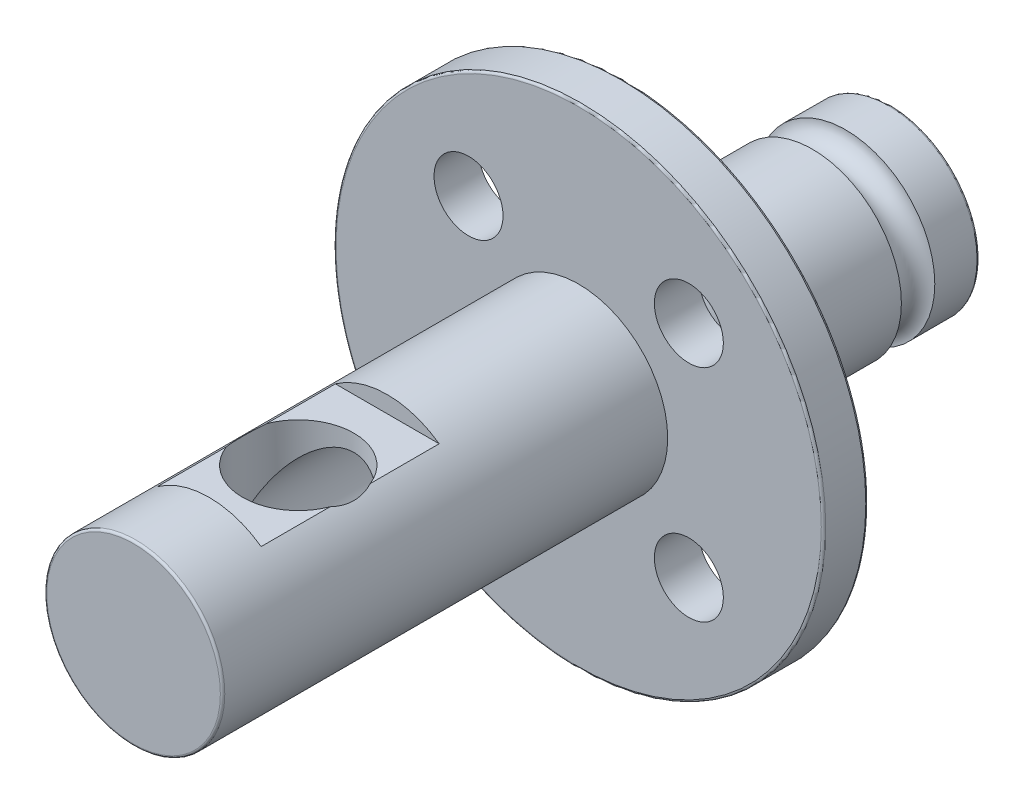
from build123d import *

# Parameters (mm, degrees)
SKETCH3_R          = 1.55
CUT_EXTRUDE1_DEPTH = 10
FILLET2_R          = 0.1
SKETCH5_W          = 5
SKETCH5_H          = 8
CUT_EXTRUDE3_DEPTH = 0.75
SKETCH6_R          = 2.5
CUT_EXTRUDE4_DEPTH = 3.25
SKETCH7_R          = 2.5
CUT_EXTRUDE5_DEPTH = 30


with BuildPart() as part:
    # Sketch2 → Revolve1 (revolve)
    with BuildSketch(Plane(origin=(0, 0, 0), x_dir=(0, 0, -1), z_dir=(1, 0, 0))):
        with BuildLine():
            Line((-17, 0), (17, 0))
            Line((17, 0), (17, -4))
            Line((17, -4), (15, -4))
            ThreePointArc((15, -4), (14.25, -3.25), (13.5, -4))
            Line((13.5, -4), (5, -4))
            Line((5, -4), (5, -11))
            Line((5, -11), (3, -11))
            Line((3, -11), (3, -4))
            Line((3, -4), (-17, -4))
            Line((-17, -4), (-17, 0))
        make_face()
    revolve(axis=Axis((0, 0, 17), (0, 0, -1)))

    # Sketch3 → Cut-Extrude1 (cut)
    with BuildSketch(Plane.XY.offset(-3)):
        with Locations((-4.949747468, 4.949747468)):
            Circle(SKETCH3_R)
        with Locations((4.949747468, 4.949747468)):
            Circle(SKETCH3_R)
        with Locations((4.949747468, -4.949747468)):
            Circle(SKETCH3_R)
        with Locations((-4.949747468, -4.949747468)):
            Circle(SKETCH3_R)
    extrude(amount=-CUT_EXTRUDE1_DEPTH, mode=Mode.SUBTRACT)

    # Fillet2
    fillet2_edges = [part.edges().sort_by_distance(p)[0] for p in [
        (0, 4, -17),
        (0, 4, 17),
        (0, 11, -3),
        (0, 11, -5),
    ]]
    fillet(fillet2_edges, radius=FILLET2_R)

    # Sketch5 → Cut-Extrude3 (cut)
    with BuildSketch(Plane(origin=(0, 4, 0), x_dir=(1, 0, 0), z_dir=(0, 1, 0))):
        with Locations((0, -9.6)):
            Rectangle(SKETCH5_W, SKETCH5_H)
    extrude(amount=-CUT_EXTRUDE3_DEPTH, mode=Mode.SUBTRACT)

    # Sketch6 → Cut-Extrude4 (cut)
    with BuildSketch(Plane(origin=(0, 3.25, 0), x_dir=(1, 0, 0), z_dir=(0, 1, 0))):
        with Locations((0, -9.6)):
            Circle(SKETCH6_R)
    extrude(amount=-CUT_EXTRUDE4_DEPTH, mode=Mode.SUBTRACT)

    # Sketch7 → Cut-Extrude5 (cut)
    with BuildSketch(Plane(origin=(0, 0, -17), x_dir=(-1, 0, 0), z_dir=(0, 0, -1))):
        Circle(SKETCH7_R)
    extrude(amount=-CUT_EXTRUDE5_DEPTH, mode=Mode.SUBTRACT)


solid = part.part
